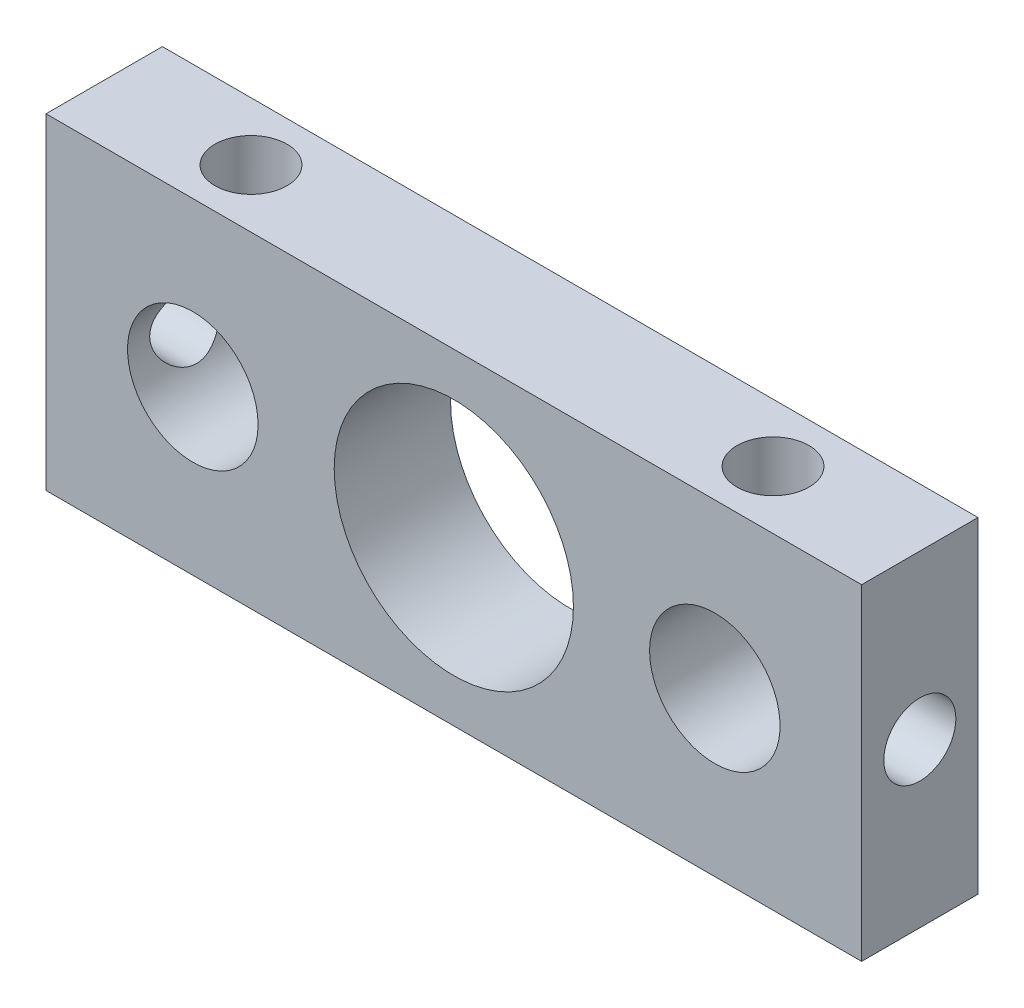
from build123d import *

# Parameters (mm, degrees)
ESBO_O1_W                                   = 75
ESBO_O1_H                                   = 30
RESSALTO_EXTRUS_O1_DEPTH                    = 10.7
ESBO_O2_R                                   = 6
CORTE_EXTRUS_O1_DEPTH                       = 11.7
ESBO_O7_R                                   = 11
CORTE_EXTRUS_O6_DEPTH                       = 11.7
FURO_ROSCADO_PARA_CONDU_TE_DE_1_4_281_D     = 6.6294
FURO_ROSCADO_PARA_CONDU_TE_DE_1_4_281_DEPTH = 15
FURO_ROSCADO_PARA_CONDU_TE_DE_1_4_281_TIP   = 1.991672694
FURO_ROSCADO_PARA_CONDU_TE_DE_1_4_282_D     = 6.6294
FURO_ROSCADO_PARA_CONDU_TE_DE_1_4_282_DEPTH = 15
FURO_ROSCADO_PARA_CONDU_TE_DE_1_4_282_TIP   = 1.991672694
FURO_ROSCADO_PARA_CONDU_TE_DE_1_4_283_D     = 6.6294
FURO_ROSCADO_PARA_CONDU_TE_DE_1_4_283_DEPTH = 15
FURO_ROSCADO_PARA_CONDU_TE_DE_1_4_283_TIP   = 1.991672694
FURO_ROSCADO_PARA_CONDU_TE_DE_1_4_284_D     = 6.6294
FURO_ROSCADO_PARA_CONDU_TE_DE_1_4_284_DEPTH = 12
FURO_ROSCADO_PARA_CONDU_TE_DE_1_4_284_TIP   = 1.991672694


with BuildPart() as part:
    # Esboço1 → Ressalto-extrusão1 (new body)
    with BuildSketch(Plane.XY):
        Rectangle(ESBO_O1_W, ESBO_O1_H)
    extrude(amount=RESSALTO_EXTRUS_O1_DEPTH)

    # Esboço2 → Corte-extrusão1 (cut, through all)
    with BuildSketch(Plane.XY.offset(10.7)):
        with Locations((-24, 0)):
            Circle(ESBO_O2_R)
        with Locations((24, 0)):
            Circle(ESBO_O2_R)
    extrude(amount=-CORTE_EXTRUS_O1_DEPTH, mode=Mode.SUBTRACT)

    # Esboço7 → Corte-extrusão6 (cut, through all)
    with BuildSketch(Plane.XY.offset(10.7)):
        Circle(ESBO_O7_R)
    extrude(amount=-CORTE_EXTRUS_O6_DEPTH, mode=Mode.SUBTRACT)

    # Furo roscado para conduíte de 1/4-281
    with Locations(Plane(origin=(0, 15, 0), x_dir=(1, 0, 0), z_dir=(0, 1, 0))):
        with Locations((-24, -5.35), (24, -5.35)):
            Hole(FURO_ROSCADO_PARA_CONDU_TE_DE_1_4_281_D / 2, depth=FURO_ROSCADO_PARA_CONDU_TE_DE_1_4_281_DEPTH)
            with Locations((0, 0, -(FURO_ROSCADO_PARA_CONDU_TE_DE_1_4_281_DEPTH + FURO_ROSCADO_PARA_CONDU_TE_DE_1_4_281_TIP / 2))):  # 118° drill point
                Cone(0, FURO_ROSCADO_PARA_CONDU_TE_DE_1_4_281_D / 2, FURO_ROSCADO_PARA_CONDU_TE_DE_1_4_281_TIP, mode=Mode.SUBTRACT)

    # Furo roscado para conduíte de 1/4-282
    with Locations(Plane.ZY.offset(37.5)):
        with Locations((5.35, 0)):
            Hole(FURO_ROSCADO_PARA_CONDU_TE_DE_1_4_282_D / 2, depth=FURO_ROSCADO_PARA_CONDU_TE_DE_1_4_282_DEPTH)
            with Locations((0, 0, -(FURO_ROSCADO_PARA_CONDU_TE_DE_1_4_282_DEPTH + FURO_ROSCADO_PARA_CONDU_TE_DE_1_4_282_TIP / 2))):  # 118° drill point
                Cone(0, FURO_ROSCADO_PARA_CONDU_TE_DE_1_4_282_D / 2, FURO_ROSCADO_PARA_CONDU_TE_DE_1_4_282_TIP, mode=Mode.SUBTRACT)

    # Furo roscado para conduíte de 1/4-283
    with Locations(Plane(origin=(37.5, 0, 0), x_dir=(0, 0, -1), z_dir=(1, 0, 0))):
        with Locations((-5.35, 0)):
            Hole(FURO_ROSCADO_PARA_CONDU_TE_DE_1_4_283_D / 2, depth=FURO_ROSCADO_PARA_CONDU_TE_DE_1_4_283_DEPTH)
            with Locations((0, 0, -(FURO_ROSCADO_PARA_CONDU_TE_DE_1_4_283_DEPTH + FURO_ROSCADO_PARA_CONDU_TE_DE_1_4_283_TIP / 2))):  # 118° drill point
                Cone(0, FURO_ROSCADO_PARA_CONDU_TE_DE_1_4_283_D / 2, FURO_ROSCADO_PARA_CONDU_TE_DE_1_4_283_TIP, mode=Mode.SUBTRACT)

    # Furo roscado para conduíte de 1/4-284
    with Locations(Plane(origin=(0, -15, 0), x_dir=(-1, 0, 0), z_dir=(0, -1, 0))):
        with Locations((15, -5.35), (-15, -5.35)):
            Hole(FURO_ROSCADO_PARA_CONDU_TE_DE_1_4_284_D / 2, depth=FURO_ROSCADO_PARA_CONDU_TE_DE_1_4_284_DEPTH)
            with Locations((0, 0, -(FURO_ROSCADO_PARA_CONDU_TE_DE_1_4_284_DEPTH + FURO_ROSCADO_PARA_CONDU_TE_DE_1_4_284_TIP / 2))):  # 118° drill point
                Cone(0, FURO_ROSCADO_PARA_CONDU_TE_DE_1_4_284_D / 2, FURO_ROSCADO_PARA_CONDU_TE_DE_1_4_284_TIP, mode=Mode.SUBTRACT)


solid = part.part
